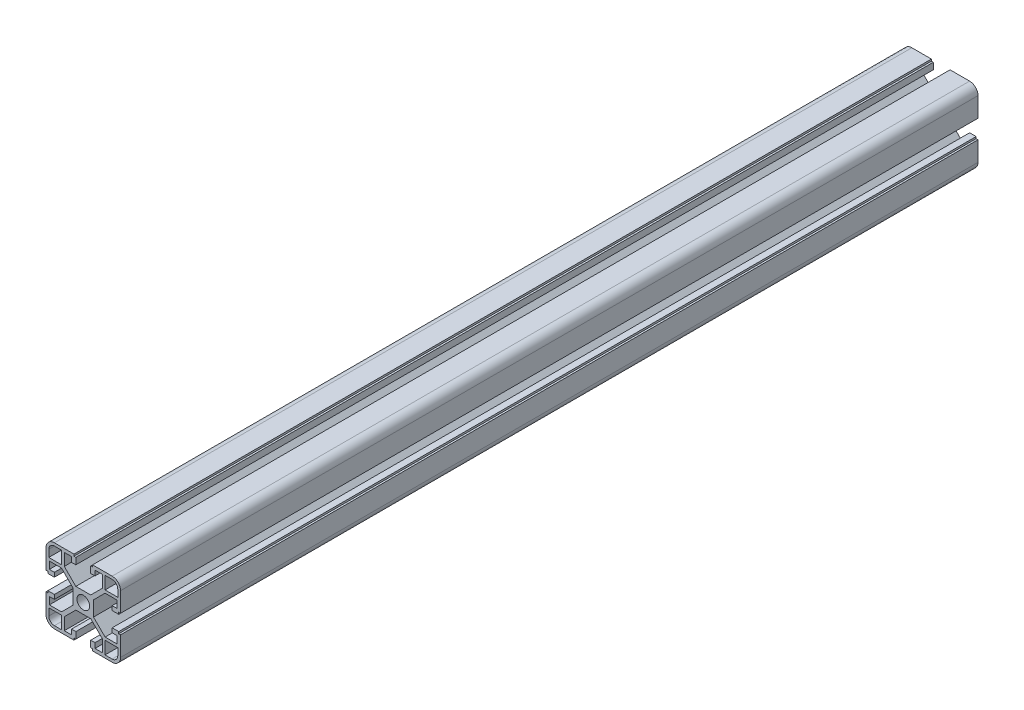
from build123d import *

# Parameters (mm, degrees)
BOSS_EXTRUDE1_DEPTH  = 460
MIRROR3_COPY_1_DEPTH = 460
MIRROR3_COPY_2_DEPTH = 460


with BuildPart() as part:
    # Sketch1 → Boss-Extrude1 (new body)
    with BuildSketch(Plane.XY):
        with BuildLine():
            Line((3.4, 0), (5.5, 0))
            Line((5.5, 0), (5.5, 4))
            Line((5.5, 4), (11.69, 10.19))
            Line((11.69, 10.19), (18.2, 10.19))
            Line((18.2, 10.19), (18.2, 6.3))
            Line((18.2, 6.3), (15.5, 6.3))
            Line((15.5, 6.3), (15.5, 4))
            Line((15.5, 4), (19, 4))
            Line((19, 4), (19, 5))
            Line((19, 5), (20, 5))
            Line((20, 5), (20, 15.5))
            ThreePointArc((20, 15.5), (18.681980515, 18.681980515), (15.5, 20))
            Line((15.5, 20), (5, 20))
            Line((5, 20), (5, 19))
            Line((5, 19), (4, 19))
            Line((4, 19), (4, 15.5))
            Line((4, 15.5), (6.3, 15.5))
            Line((6.3, 15.5), (6.3, 18.2))
            Line((6.3, 18.2), (10.19, 18.2))
            Line((10.19, 18.2), (10.19, 11.69))
            Line((10.19, 11.69), (4, 5.5))
            Line((4, 5.5), (0, 5.5))
            Line((0, 5.5), (0, 3.4))
            ThreePointArc((0, 3.4), (2.404163056, 2.404163056), (3.4, 0))
        make_face()
        with BuildLine():
            Line((18.5, 11.69), (18.5, 15.5))
            ThreePointArc((18.5, 15.5), (17.621320344, 17.621320344), (15.5, 18.5))
            Line((15.5, 18.5), (11.69, 18.5))
            Line((11.69, 18.5), (11.69, 11.69))
            Line((11.69, 11.69), (18.5, 11.69))
        make_face(mode=Mode.SUBTRACT)
    boss_extrude1 = extrude(amount=BOSS_EXTRUDE1_DEPTH)

    # Mirror1: Boss-Extrude1 across plane
    add(boss_extrude1.mirror(Plane.ZX))

    # Mirror2: Boss-Extrude1 across plane
    add(boss_extrude1.mirror(Plane(origin=(0, 0, 0), x_dir=(0, 0, 1), z_dir=(1, 0, 0))))

    # Mirror3 copy 1 sketch → Mirror3 copy 1 (add)
    with BuildSketch(Plane(origin=(0, 0, 0), x_dir=(-1, 0, 0), z_dir=(0, 0, 1))):
        with BuildLine():
            Line((3.4, 0), (5.5, 0))
            Line((5.5, 0), (5.5, 4))
            Line((5.5, 4), (11.69, 10.19))
            Line((11.69, 10.19), (18.2, 10.19))
            Line((18.2, 10.19), (18.2, 6.3))
            Line((18.2, 6.3), (15.5, 6.3))
            Line((15.5, 6.3), (15.5, 4))
            Line((15.5, 4), (19, 4))
            Line((19, 4), (19, 5))
            Line((19, 5), (20, 5))
            Line((20, 5), (20, 15.5))
            ThreePointArc((20, 15.5), (18.681980515, 18.681980515), (15.5, 20))
            Line((15.5, 20), (5, 20))
            Line((5, 20), (5, 19))
            Line((5, 19), (4, 19))
            Line((4, 19), (4, 15.5))
            Line((4, 15.5), (6.3, 15.5))
            Line((6.3, 15.5), (6.3, 18.2))
            Line((6.3, 18.2), (10.19, 18.2))
            Line((10.19, 18.2), (10.19, 11.69))
            Line((10.19, 11.69), (4, 5.5))
            Line((4, 5.5), (0, 5.5))
            Line((0, 5.5), (0, 3.4))
            ThreePointArc((0, 3.4), (2.404163056, 2.404163056), (3.4, 0))
        make_face()
        with BuildLine():
            Line((18.5, 11.69), (18.5, 15.5))
            ThreePointArc((18.5, 15.5), (17.621320344, 17.621320344), (15.5, 18.5))
            Line((15.5, 18.5), (11.69, 18.5))
            Line((11.69, 18.5), (11.69, 11.69))
            Line((11.69, 11.69), (18.5, 11.69))
        make_face(mode=Mode.SUBTRACT)
    extrude(amount=MIRROR3_COPY_1_DEPTH)

    # Mirror3 copy 2 sketch → Mirror3 copy 2 (add)
    with BuildSketch(Plane.XY):
        with BuildLine():
            Line((3.4, 0), (5.5, 0))
            Line((5.5, 0), (5.5, -4))
            Line((5.5, -4), (11.69, -10.19))
            Line((11.69, -10.19), (18.2, -10.19))
            Line((18.2, -10.19), (18.2, -6.3))
            Line((18.2, -6.3), (15.5, -6.3))
            Line((15.5, -6.3), (15.5, -4))
            Line((15.5, -4), (19, -4))
            Line((19, -4), (19, -5))
            Line((19, -5), (20, -5))
            Line((20, -5), (20, -15.5))
            ThreePointArc((20, -15.5), (18.681980515, -18.681980515), (15.5, -20))
            Line((15.5, -20), (5, -20))
            Line((5, -20), (5, -19))
            Line((5, -19), (4, -19))
            Line((4, -19), (4, -15.5))
            Line((4, -15.5), (6.3, -15.5))
            Line((6.3, -15.5), (6.3, -18.2))
            Line((6.3, -18.2), (10.19, -18.2))
            Line((10.19, -18.2), (10.19, -11.69))
            Line((10.19, -11.69), (4, -5.5))
            Line((4, -5.5), (0, -5.5))
            Line((0, -5.5), (0, -3.4))
            ThreePointArc((0, -3.4), (2.404163056, -2.404163056), (3.4, 0))
        make_face()
        with BuildLine():
            Line((18.5, -11.69), (18.5, -15.5))
            ThreePointArc((18.5, -15.5), (17.621320344, -17.621320344), (15.5, -18.5))
            Line((15.5, -18.5), (11.69, -18.5))
            Line((11.69, -18.5), (11.69, -11.69))
            Line((11.69, -11.69), (18.5, -11.69))
        make_face(mode=Mode.SUBTRACT)
    extrude(amount=MIRROR3_COPY_2_DEPTH)


solid = part.part
